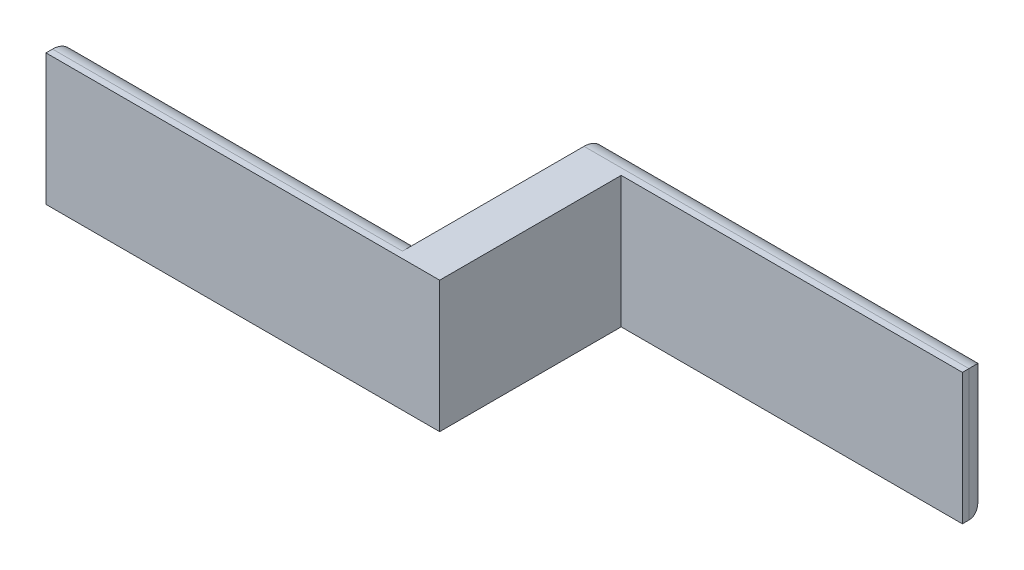
from build123d import *

# Parameters (mm, degrees)
SKETCH2_W           = 12.7
SKETCH2_H           = 44.45
BOSS_EXTRUDE1_DEPTH = 38.1
FILLET1_R           = 6.35


with BuildPart() as part:
    # Sketch2 → Boss-Extrude1 (new body)
    with BuildSketch(Plane(origin=(0, 0, 0), x_dir=(1, 0, 0), z_dir=(0, 1, 0))):
        Polygon((0, 8.255), (0, 0), (114.3, 0), (114.3, 8.255), (101.6, 8.255), align=None)
        with Locations((107.95, 30.48)):
            Rectangle(SKETCH2_W, SKETCH2_H)
        Polygon((101.6, 52.705), (114.3, 52.705), (213.36, 52.705), (213.36, 60.96), (101.6, 60.96), align=None)
    extrude(amount=BOSS_EXTRUDE1_DEPTH)

    # Fillet1
    fillet1_edges = [part.edges().sort_by_distance(p)[0] for p in [
        (50.8, 0, -8.255),
        (157.48, 0, -60.96),
        (213.36, 19.05, -60.96),
        (157.48, 38.1, -60.96),
        (50.8, 38.1, -8.255),
    ]]
    fillet(fillet1_edges, radius=FILLET1_R)


solid = part.part
